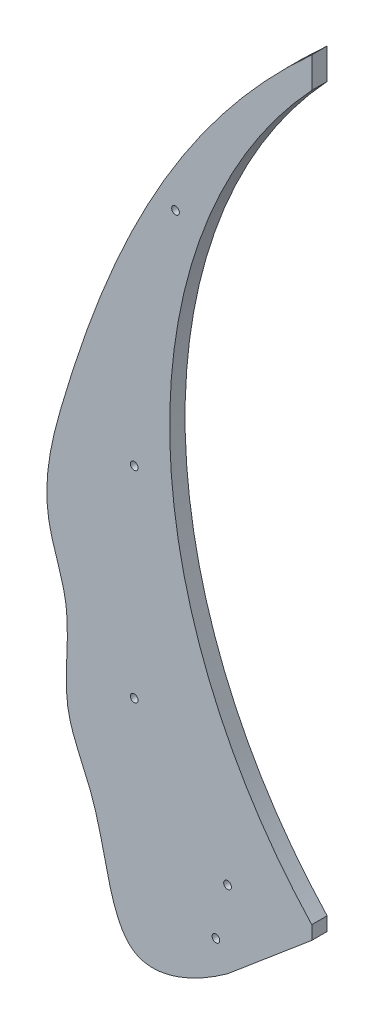
from build123d import *

# Parameters (mm, degrees)
SKETCH3_R           = 2.5
BOSS_EXTRUDE1_DEPTH = 10


with BuildPart() as part:
    # Sketch3 → Boss-Extrude1 (new body)
    with BuildSketch(Plane.XY):
        with BuildLine():
            Line((0, 490), (0, 470))
            ThreePointArc((0, 470), (-92.413381194, 235), (0, 0))
            Line((0, 0), (0, -8.867768956))
            Line((0, -8.867768956), (-54.715396563, -55))
            add(Edge.make_bspline(
                [(-54.715396563, -55), (-77.500010104, -71.410542433), (-130.437818625, -93.125533591), (-133.749361855, -8.323121335), (-166.063985478, 44.01392087), (-153.216703704, 95.628729379), (-178.978394968, 151.156197499), (-140.629316159, 299.758982487), (-83.988063243, 413.799917365), (0, 490)],
                knots=[0.101497079, 0.101497079, 0.101497079, 0.101497079, 0.185559624, 0.290899105, 0.346088729, 0.429575015, 0.479308889, 0.578896021, 1, 1, 1, 1], degree=3))
        make_face()
        with Locations((-54.772255751, -5)):
            Circle(SKETCH3_R, mode=Mode.SUBTRACT)
        with Locations((-62.359405203, -38.893919331)):
            Circle(SKETCH3_R, mode=Mode.SUBTRACT)
        with Locations((-115.495699517, 69.807446598)):
            Circle(SKETCH3_R, mode=Mode.SUBTRACT)
        with Locations((-115.495699517, 200.727236705)):
            Circle(SKETCH3_R, mode=Mode.SUBTRACT)
        with Locations((-88.605903344, 358.102068825)):
            Circle(SKETCH3_R, mode=Mode.SUBTRACT)
    extrude(amount=BOSS_EXTRUDE1_DEPTH)


solid = part.part
